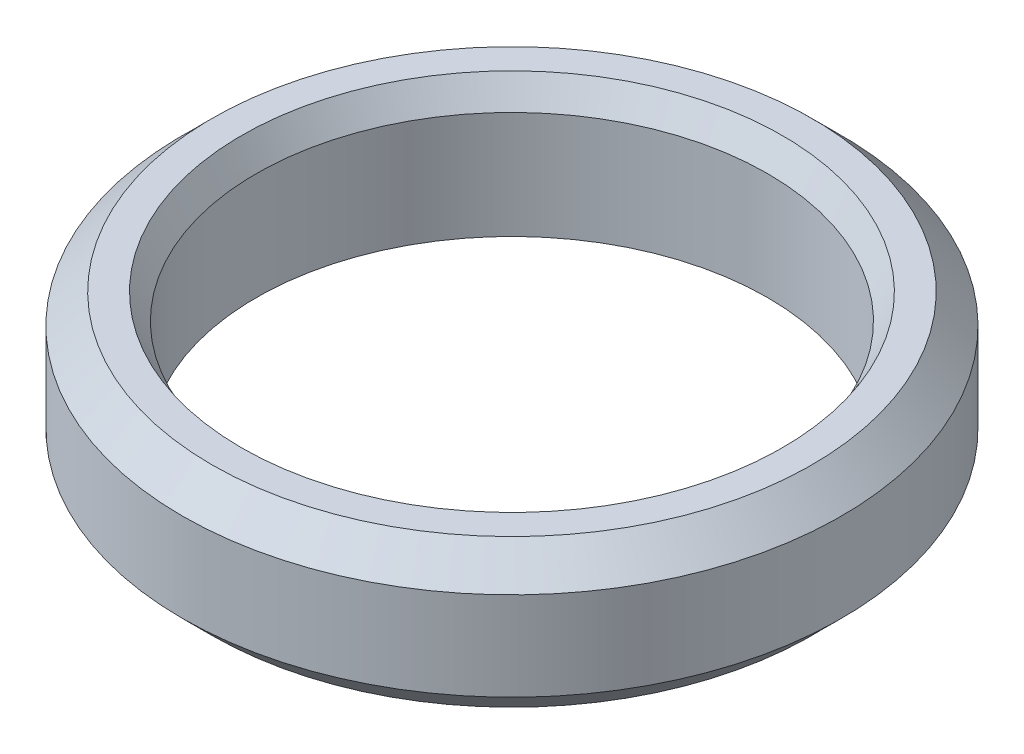
from build123d import *

# Parameters (mm, degrees)
SKETCH1_R             = 11.15
SKETCH1_R_2           = 8.65
BOSS_EXTRUDE1_DEPTH   = 5
CHAMFER1_SIZE         = 1
CHAMFER2_SIZE         = 0.5
CHAMFER2_SIZE2        = 0.866025404
CHAMFER2_PART_2_SIZE  = 0.5
CHAMFER2_PART_2_SIZE2 = 0.866025404


with BuildPart() as part:
    # Sketch1 → Boss-Extrude1 (new body)
    with BuildSketch(Plane(origin=(0, 0, 0), x_dir=(1, 0, 0), z_dir=(0, 1, 0))):
        Circle(SKETCH1_R)
        Circle(SKETCH1_R_2, mode=Mode.SUBTRACT)
    extrude(amount=BOSS_EXTRUDE1_DEPTH)

    # Chamfer1
    chamfer1_edges = [part.edges().sort_by_distance(p)[0] for p in [
        (-11.15, 0, 0),
        (-11.15, 5, 0),
    ]]
    chamfer(chamfer1_edges, length=CHAMFER1_SIZE)

    # Chamfer2
    chamfer2_edges = [part.edges().sort_by_distance(p)[0] for p in [
        (-8.65, 0, 0),
    ]]
    chamfer2_side = [part.faces().sort_by_distance(p)[0] for p in [
        (-8.65, 2.5, 0),
    ]]
    chamfer(chamfer2_edges, length=CHAMFER2_SIZE, length2=CHAMFER2_SIZE2, reference=chamfer2_side[0])

    # Chamfer2 part 2
    chamfer2_part_2_edges = [part.edges().sort_by_distance(p)[0] for p in [
        (-8.65, 5, 0),
    ]]
    chamfer2_part_2_side = [part.faces().sort_by_distance(p)[0] for p in [
        (-9.862914647, 5, 0),
    ]]
    chamfer(chamfer2_part_2_edges, length=CHAMFER2_PART_2_SIZE, length2=CHAMFER2_PART_2_SIZE2, reference=chamfer2_part_2_side[0])


solid = part.part
